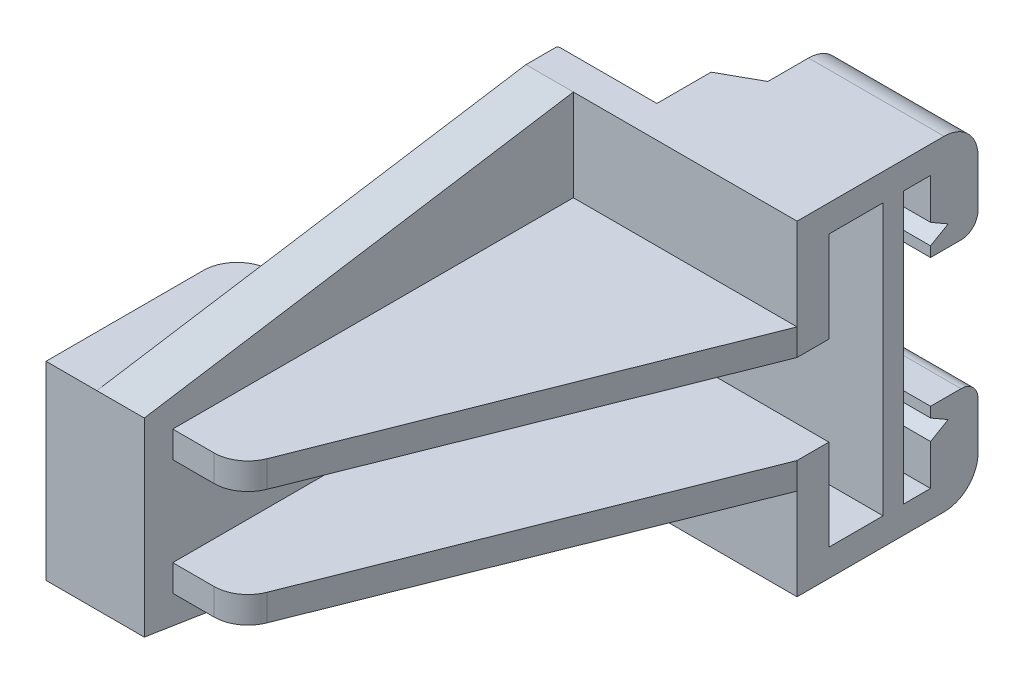
from build123d import *

# Parameters (mm, degrees)
SKETCH_1_W          = 90
SKETCH_1_H          = 48
EXTRUDE_1_DEPTH     = 40
CUT_EXTRUDE_1_DEPTH = 40
CUT_EXTRUDE_2_DEPTH = 49
CUT_EXTRUDE_3_DEPTH = 49
CUT_EXTRUDE_4_DEPTH = 33
SKETCH_6_W          = 8
SKETCH_6_H          = 40
CUT_EXTRUDE_5_DEPTH = 41
SKETCH_7_W          = 20
SKETCH_7_H          = 13.155555556
CUT_EXTRUDE_6_DEPTH = 5
SKETCH_8_W          = 28.2
SKETCH_8_H          = 28
EXTRUDE_2_DEPTH     = 7.5
SKETCH_9_R          = 2.25
EXTRUDE_3_DEPTH     = 4
SKETCH_10_R         = 1.2
CUT_EXTRUDE_7_DEPTH = 84
FILLET_1_R          = 5
FILLET_2_R          = 2.5
SKETCH_11_W         = 14.62039328
SKETCH_11_H         = 48
CUT_EXTRUDE_8_DEPTH = 10


with BuildPart() as part:
    # 스케치1 → 보스-돌출1 (new body)
    with BuildSketch(Plane(origin=(0, 0, 0), x_dir=(0, 0, -1), z_dir=(1, 0, 0))):
        with Locations((45, 24)):
            Rectangle(SKETCH_1_W, SKETCH_1_H)
    extrude(amount=EXTRUDE_1_DEPTH)

    # 스케치2 → 컷-돌출1 (cut)
    with BuildSketch(Plane(origin=(40, 0, 0), x_dir=(0, 0, -1), z_dir=(1, 0, 0))):
        Polygon((79, 44), (83, 44), (83, 38), (85.598076211, 36.5), (83, 35), (83, 33.5), (90, 33.5), (90, 14.5), (83, 14.5), (83, 13), (85.598076211, 11.5), (83, 10), (83, 4), (79, 4), align=None)
        Polygon((0, 38), (63.304035288, 48), (0, 48), align=None)
        Polygon((0, 10), (63.304035288, 0), (0, 0), align=None)
    extrude(amount=-CUT_EXTRUDE_1_DEPTH, mode=Mode.SUBTRACT)

    # 스케치3 → 컷-돌출2 (cut, through all)
    with BuildSketch(Plane(origin=(0, 48, 0), x_dir=(1, 0, 0), z_dir=(0, 1, 0))):
        Polygon((0, 67.846768337), (20, 79), (20, 90), (0, 90), align=None)
    extrude(amount=-CUT_EXTRUDE_2_DEPTH, mode=Mode.SUBTRACT)

    # 스케치4 → 컷-돌출3 (cut, through all)
    with BuildSketch(Plane(origin=(0, 48, 0), x_dir=(1, 0, 0), z_dir=(0, 1, 0))):
        Polygon((40, 63.304035288), (14.807552651, 0), (40, 0), align=None)
    extrude(amount=-CUT_EXTRUDE_3_DEPTH, mode=Mode.SUBTRACT)

    # 스케치5 → 컷-돌출4 (cut)
    with BuildSketch(Plane(origin=(40, 0, 0), x_dir=(0, 0, -1), z_dir=(1, 0, 0))):
        Polygon((4.2, 34.488888889), (63.304035288, 34.488888889), (63.304035288, 48), (0, 38), (0, 10), (63.304035288, 0), (63.304035288, 13.511111111), (4.2, 13.511111111), (4.2, 17.422222222), (63.304035288, 17.422222222), (63.304035288, 30.577777778), (4.2, 30.577777778), align=None)
    extrude(amount=-CUT_EXTRUDE_4_DEPTH, mode=Mode.SUBTRACT)

    # 스케치6 → 컷-돌출5 (cut, through all)
    with BuildSketch(Plane(origin=(40, 0, 0), x_dir=(0, 0, -1), z_dir=(1, 0, 0))):
        with Locations((72, 24)):
            Rectangle(SKETCH_6_W, SKETCH_6_H)
    extrude(amount=-CUT_EXTRUDE_5_DEPTH, mode=Mode.SUBTRACT)

    # 스케치7 → 컷-돌출6 (cut)
    with BuildSketch(Plane.XY.offset(-63.304035288)):
        with Locations((30, 24)):
            Rectangle(SKETCH_7_W, SKETCH_7_H)
    extrude(amount=-CUT_EXTRUDE_6_DEPTH, mode=Mode.SUBTRACT)

    # 스케치8 → 보스-돌출2 (add)
    with BuildSketch(Plane.ZY):
        with Locations((-14.1, 24)):
            Rectangle(SKETCH_8_W, SKETCH_8_H)
    extrude(amount=EXTRUDE_2_DEPTH)

    # 스케치9 → 보스-돌출3 (add)
    with BuildSketch(Plane(origin=(0, 0, -79), x_dir=(-1, 0, 0), z_dir=(0, 0, -1))):
        with Locations((-30, 24)):
            Circle(SKETCH_9_R)
    extrude(amount=EXTRUDE_3_DEPTH)

    # 스케치10 → 컷-돌출7 (cut, through all)
    with BuildSketch(Plane(origin=(0, 0, -83), x_dir=(-1, 0, 0), z_dir=(0, 0, -1))):
        with Locations((-30, 24)):
            Circle(SKETCH_10_R)
    extrude(amount=-CUT_EXTRUDE_7_DEPTH, mode=Mode.SUBTRACT)

    # 필렛1
    fillet_1_edges = [part.edges().sort_by_distance(p)[0] for p in [
        (16.47898289, 32.533333333, -4.2),
        (16.47898289, 15.466666667, -4.2),
        (-7.5, 24, -28.2),
        (30, 48, -90),
        (30, 0, -90),
    ]]
    fillet(fillet_1_edges, radius=FILLET_1_R)

    # 필렛2
    fillet_2_edges = [part.edges().sort_by_distance(p)[0] for p in [
        (30, 14.5, -90),
        (30, 33.5, -90),
    ]]
    fillet(fillet_2_edges, radius=FILLET_2_R)

    # 스케치11 → 컷-돌출8 (cut)
    with BuildSketch(Plane(origin=(0, 0, -68), x_dir=(-1, 0, 0), z_dir=(0, 0, -1))):
        with Locations((-7.31019664, 24)):
            Rectangle(SKETCH_11_W, SKETCH_11_H)
    extrude(amount=CUT_EXTRUDE_8_DEPTH, mode=Mode.SUBTRACT)


solid = part.part
